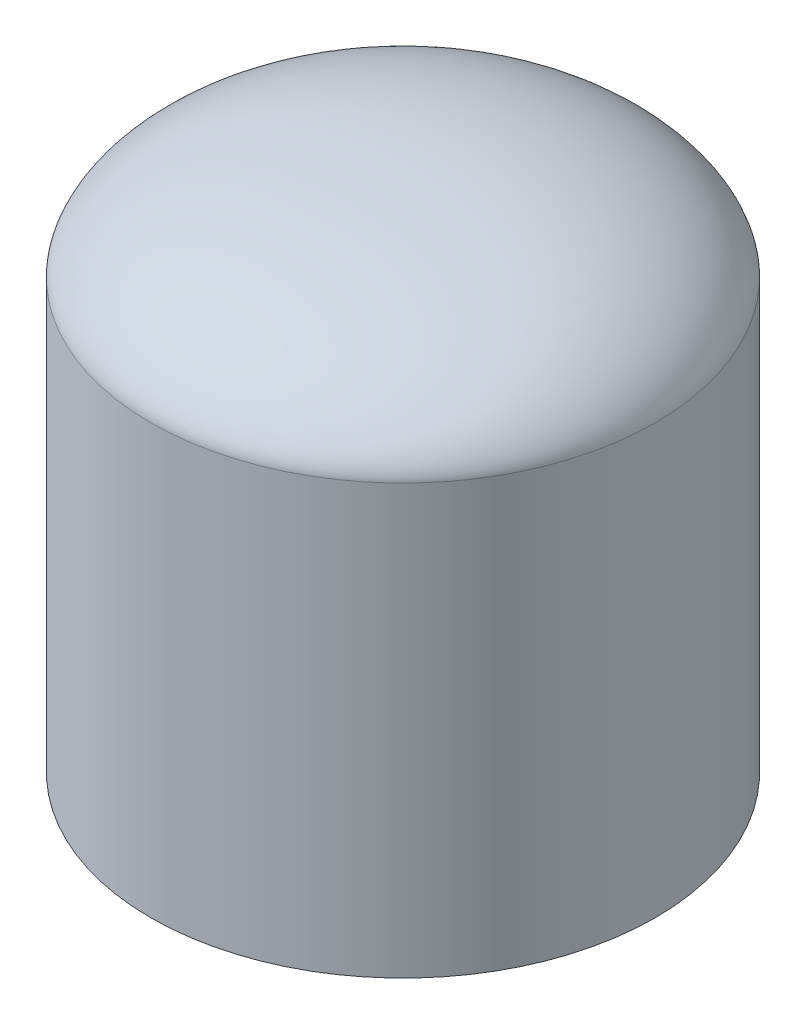
from build123d import *


with BuildPart() as part:
    # Esquisse1 → Révolution1 (revolve)
    with BuildSketch(Plane.XY):
        with BuildLine():
            Line((-5, 0), (-5, -8.5))
            Line((-5, -8.5), (0, -8.5))
            Line((0, -8.5), (0, 2))
            add(Edge.make_bspline(
                [(0, 2), (-3.814674298, 2), (-5, 0.453980543), (-5, 0)],
                knots=[0, 0, 0, 0, 1, 1, 1, 1], degree=3))
        make_face()
    revolve(axis=Axis((0, -8.5, 0), (0, 1, 0)))


solid = part.part
